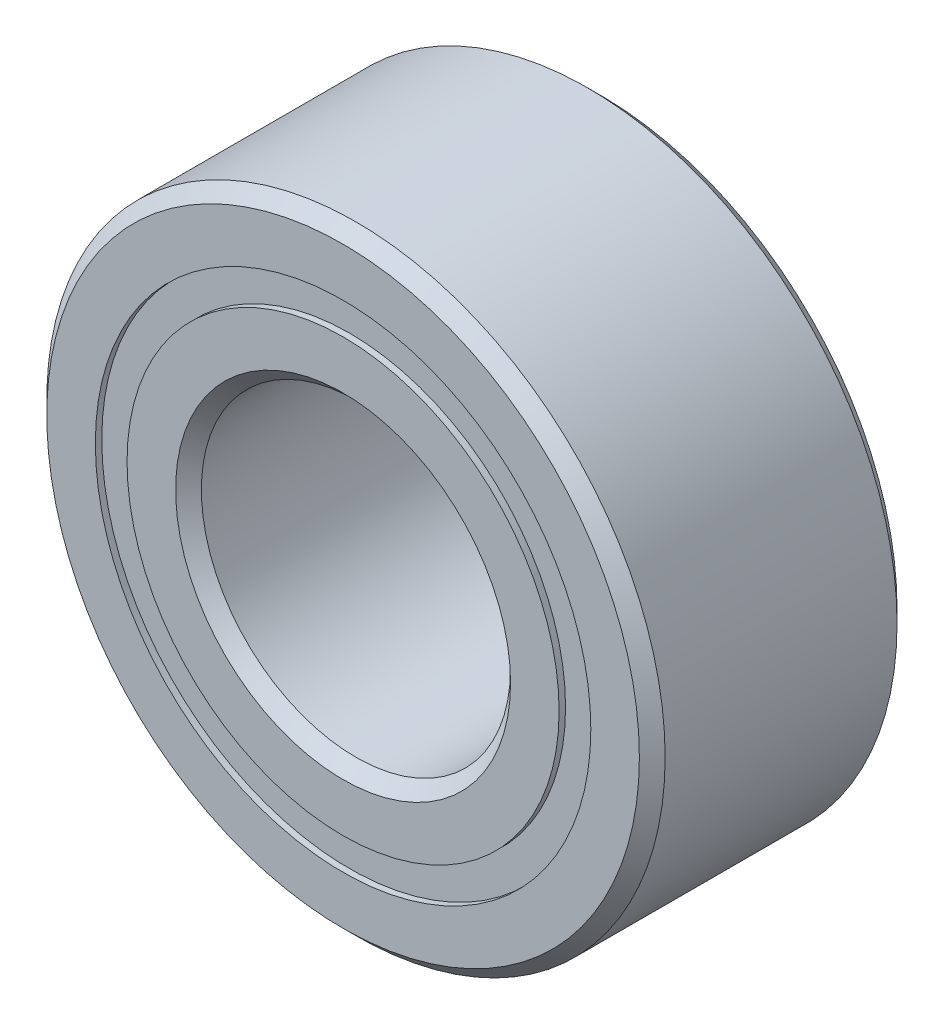
from build123d import *

# Parameters (mm, degrees)
CIRPATTERN1_COUNT = 12
SKETCH5_W         = 0.611036112
SKETCH5_H         = 0.307692308


with BuildPart() as part:
    # Sketch1 → Revolve1 (revolve)
    with BuildSketch(Plane(origin=(0, 0, 0), x_dir=(0, 0, -1), z_dir=(1, 0, 0))):
        with BuildLine():
            Line((1.125, 3), (-1.125, 3))
            Line((-1.125, 3), (-1.25, 2.875))
            Line((-1.25, 2.875), (-1.25, 2.403846154))
            Line((-1.25, 2.403846154), (-0.555555556, 2.403846154))
            ThreePointArc((-0.555555556, 2.403846154), (0, 2.826463888), (0.555555556, 2.403846154))
            Line((0.555555556, 2.403846154), (1.25, 2.403846154))
            Line((1.25, 2.403846154), (1.25, 2.875))
            Line((1.25, 2.875), (1.125, 3))
        make_face()
    revolve(axis=Axis((0, 0, 1.25), (0, 0, -1)))


with BuildPart() as body_2:
    # Sketch3 → Revolve3 (revolve)
    with BuildSketch(Plane(origin=(0, 0, 0), x_dir=(0, 0, -1), z_dir=(1, 0, 0))):
        with BuildLine():
            Line((-1.25, 2.096153846), (-0.555555556, 2.096153846))
            ThreePointArc((-0.555555556, 2.096153846), (0, 1.673536112), (0.555555556, 2.096153846))
            Line((0.555555556, 2.096153846), (1.25, 2.096153846))
            Line((1.25, 2.096153846), (1.25, 1.625))
            Line((1.25, 1.625), (1.125, 1.5))
            Line((1.125, 1.5), (-1.125, 1.5))
            Line((-1.125, 1.5), (-1.25, 1.625))
            Line((-1.25, 1.625), (-1.25, 2.096153846))
        make_face()
    revolve(axis=Axis((0, 0, 1.25), (0, 0, -1)))


with BuildPart() as body_3:
    # Sketch4 → Revolve4 (revolve)
    with BuildSketch(Plane(origin=(0, 0, 0), x_dir=(0, 0, -1), z_dir=(1, 0, 0))):
        with BuildLine():
            Line((-0.576463888, 2.25), (0.576463888, 2.25))
            ThreePointArc((0.576463888, 2.25), (0, 2.826463888), (-0.576463888, 2.25))
        make_face()
    revolve(axis=Axis((0, 2.25, 0.576463888), (0, 0, -1)))


with BuildPart() as cirpattern1_1:
    # CirPattern1: pattern copy
    add(body_3.part.rotate(Axis((0, 0, 0), (0, 0, 1)), 1 * 360 / CIRPATTERN1_COUNT))


with BuildPart() as cirpattern1_2:
    # CirPattern1: pattern copy
    add(body_3.part.rotate(Axis((0, 0, 0), (0, 0, 1)), 2 * 360 / CIRPATTERN1_COUNT))


with BuildPart() as cirpattern1_3:
    # CirPattern1: pattern copy
    add(body_3.part.rotate(Axis((0, 0, 0), (0, 0, 1)), 3 * 360 / CIRPATTERN1_COUNT))


with BuildPart() as cirpattern1_4:
    # CirPattern1: pattern copy
    add(body_3.part.rotate(Axis((0, 0, 0), (0, 0, 1)), 4 * 360 / CIRPATTERN1_COUNT))


with BuildPart() as cirpattern1_5:
    # CirPattern1: pattern copy
    add(body_3.part.rotate(Axis((0, 0, 0), (0, 0, 1)), 5 * 360 / CIRPATTERN1_COUNT))


with BuildPart() as cirpattern1_6:
    # CirPattern1: pattern copy
    add(body_3.part.rotate(Axis((0, 0, 0), (0, 0, 1)), 6 * 360 / CIRPATTERN1_COUNT))


with BuildPart() as cirpattern1_7:
    # CirPattern1: pattern copy
    add(body_3.part.rotate(Axis((0, 0, 0), (0, 0, 1)), 7 * 360 / CIRPATTERN1_COUNT))


with BuildPart() as cirpattern1_8:
    # CirPattern1: pattern copy
    add(body_3.part.rotate(Axis((0, 0, 0), (0, 0, 1)), 8 * 360 / CIRPATTERN1_COUNT))


with BuildPart() as cirpattern1_9:
    # CirPattern1: pattern copy
    add(body_3.part.rotate(Axis((0, 0, 0), (0, 0, 1)), 9 * 360 / CIRPATTERN1_COUNT))


with BuildPart() as cirpattern1_10:
    # CirPattern1: pattern copy
    add(body_3.part.rotate(Axis((0, 0, 0), (0, 0, 1)), 10 * 360 / CIRPATTERN1_COUNT))


with BuildPart() as cirpattern1_11:
    # CirPattern1: pattern copy
    add(body_3.part.rotate(Axis((0, 0, 0), (0, 0, 1)), 11 * 360 / CIRPATTERN1_COUNT))


with BuildPart() as body_15:
    # Sketch5 → Revolve5 (revolve)
    with BuildSketch(Plane(origin=(0, 0, 0), x_dir=(0, 0, -1), z_dir=(1, 0, 0))):
        with Locations((-0.881981944, 2.25)):
            Rectangle(SKETCH5_W, SKETCH5_H)
        with Locations((0.881981944, 2.25)):
            Rectangle(SKETCH5_W, SKETCH5_H)
    revolve(axis=Axis((0, 0, 1.25), (0, 0, -1)))


solid = Compound([part.part, body_2.part, body_3.part, cirpattern1_1.part, cirpattern1_2.part, cirpattern1_3.part, cirpattern1_4.part, cirpattern1_5.part, cirpattern1_6.part, cirpattern1_7.part, cirpattern1_8.part, cirpattern1_9.part, cirpattern1_10.part, cirpattern1_11.part, body_15.part])
